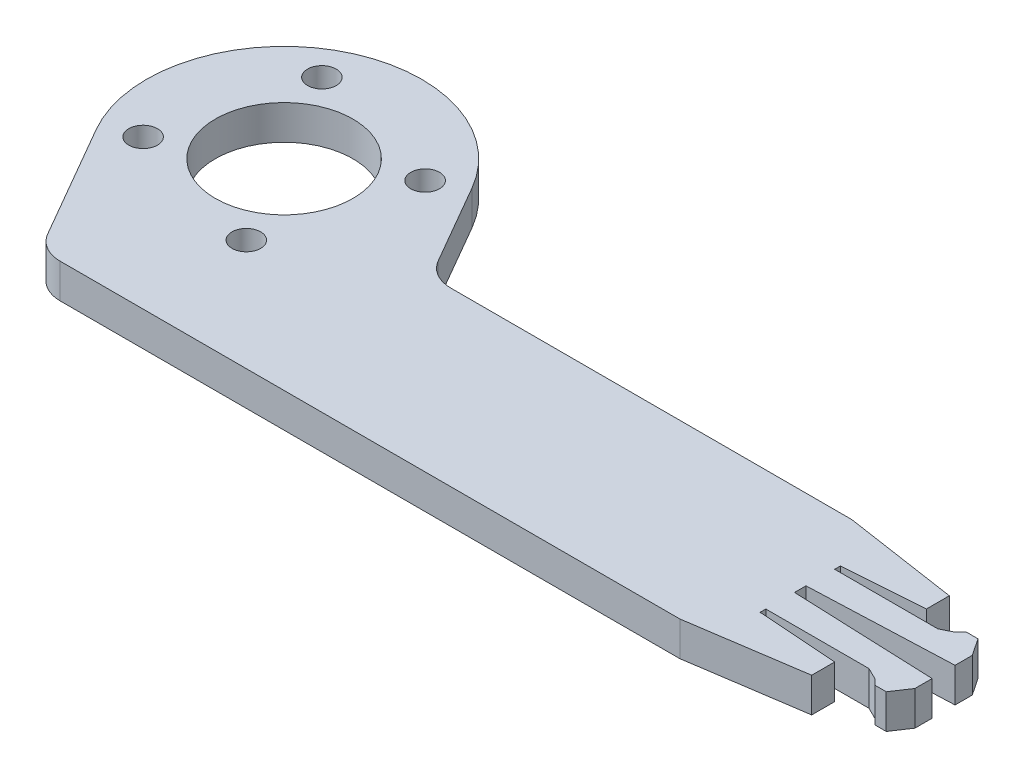
from build123d import *

# Parameters (mm, degrees)
SKETCH1_R           = 1.25
SKETCH1_R_2         = 6
BOSS_EXTRUDE1_DEPTH = 1.5
FILLET1_R           = 3


with BuildPart() as part:
    # Sketch1 → Boss-Extrude1 (new body, symmetric)
    with BuildSketch(Plane(origin=(0, 0, 0), x_dir=(1, 0, 0), z_dir=(0, 1, 0))):
        with BuildLine():
            Line((62, -16), (52, -17.5))
            Line((52, -17.5), (-3.75277675, -17.5))
            Line((-3.75277675, -17.5), (-10.392304845, -6))
            ThreePointArc((-10.392304845, -6), (-6, 10.392304845), (10.392304845, 6))
            Line((10.392304845, 6), (15.299782134, -2.5))
            Line((15.299782134, -2.5), (52, -2.5))
            Line((52, -2.5), (62, -4))
            Line((62, -4), (62, -6))
            Line((62, -6), (55, -6.5))
            Line((55, -6.5), (55, -7))
            Line((55, -7), (64, -7))
            Line((64, -7), (65, -6.5))
            Line((65, -6.5), (65.5, -6))
            Line((65.5, -6), (66.5, -6))
            Line((66.5, -6), (67.5, -7.5))
            Line((67.5, -7.5), (67.5, -9))
            Line((67.5, -9), (55, -9.5))
            Line((55, -9.5), (55, -10.5))
            Line((55, -10.5), (67.5, -11))
            Line((67.5, -11), (67.5, -12.5))
            Line((67.5, -12.5), (66.5, -14))
            Line((66.5, -14), (65.5, -14))
            Line((65.5, -14), (65, -13.5))
            Line((65, -13.5), (64, -13))
            Line((64, -13), (55, -13))
            Line((55, -13), (55, -13.5))
            Line((55, -13.5), (62, -14))
            Line((62, -14), (62, -16))
        make_face()
        with Locations((4.5, -7.794228634)):
            Circle(SKETCH1_R, mode=Mode.SUBTRACT)
        with Locations((-7.794228634, -4.5)):
            Circle(SKETCH1_R, mode=Mode.SUBTRACT)
        with Locations((-4.5, 7.794228634)):
            Circle(SKETCH1_R, mode=Mode.SUBTRACT)
        with Locations((7.794228634, 4.5)):
            Circle(SKETCH1_R, mode=Mode.SUBTRACT)
        Circle(SKETCH1_R_2, mode=Mode.SUBTRACT)
    extrude(amount=BOSS_EXTRUDE1_DEPTH, both=True)

    # Fillet1
    fillet1_edges = [part.edges().sort_by_distance(p)[0] for p in [
        (-3.75277675, 0, 17.5),
        (15.299782134, 0, 2.5),
    ]]
    fillet(fillet1_edges, radius=FILLET1_R)


solid = part.part
